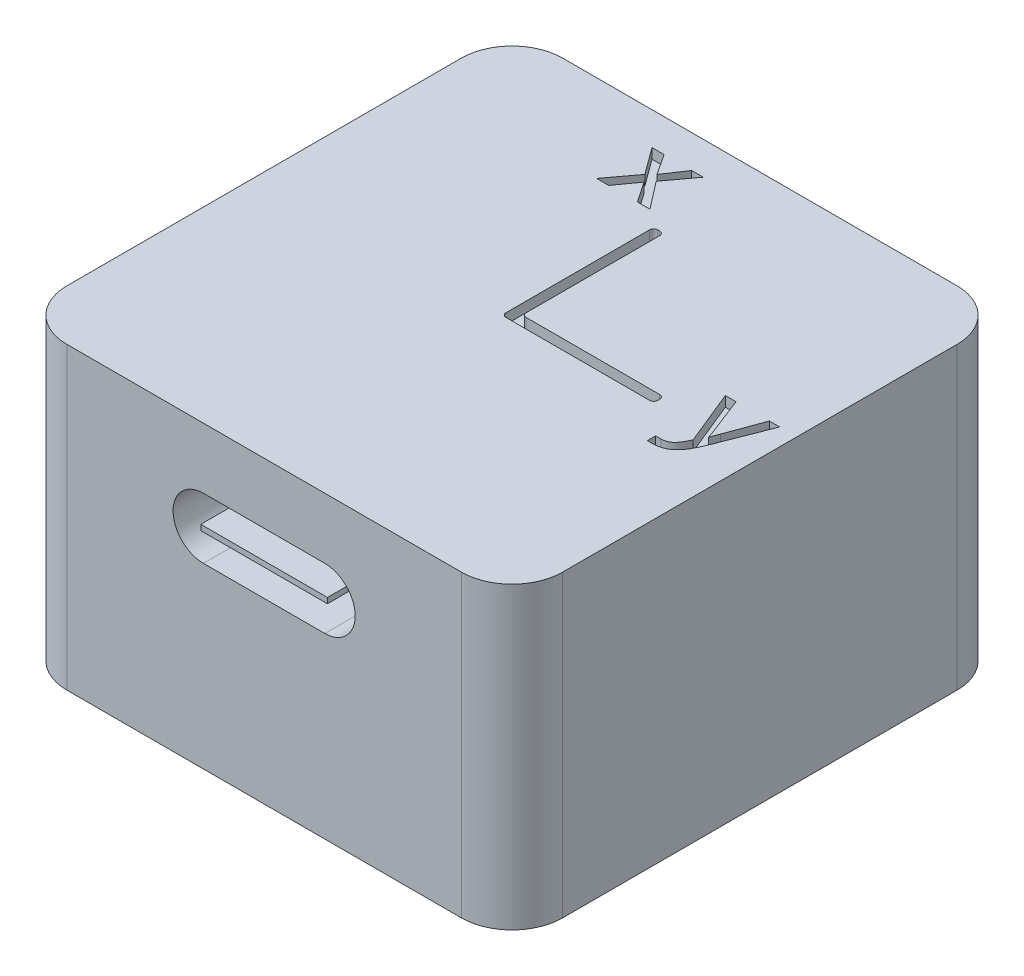
from build123d import *

# Parameters (mm, degrees)
EXTRUDE_1_DEPTH     = 14.8
CUT_EXTRUDE_1_DEPTH = 0.5
CUT_EXTRUDE_2_DEPTH = 0.5
CUT_EXTRUDE_3_DEPTH = 0.5
CUT_EXTRUDE_4_DEPTH = 5
SKETCH_6_W          = 6.25953497
SKETCH_6_H          = 0.270195754
EXTRUDE_2_DEPTH     = 5


with BuildPart() as part:
    # 草图1 → 凸台-拉伸1 (new body)
    with BuildSketch(Plane(origin=(0, 0, 0), x_dir=(1, 0, 0), z_dir=(0, 1, 0))):
        with BuildLine():
            Line((-9.75, 12.25), (9.75, 12.25))
            ThreePointArc((9.75, 12.25), (11.517766953, 11.517766953), (12.25, 9.75))
            Line((12.25, 9.75), (12.25, -9.75))
            ThreePointArc((12.25, -9.75), (11.517766953, -11.517766953), (9.75, -12.25))
            Line((9.75, -12.25), (-9.75, -12.25))
            ThreePointArc((-9.75, -12.25), (-11.517766953, -11.517766953), (-12.25, -9.75))
            Line((-12.25, -9.75), (-12.25, 9.75))
            ThreePointArc((-12.25, 9.75), (-11.517766953, 11.517766953), (-9.75, 12.25))
        make_face()
    extrude(amount=EXTRUDE_1_DEPTH)

    # 草图2 → 切除-拉伸1 (cut)
    with BuildSketch(Plane(origin=(0, 14.8, 0), x_dir=(1, 0, 0), z_dir=(0, 1, 0))):
        with BuildLine():
            Line((-0.25, -0.05), (-0.25, 7.05))
            ThreePointArc((-0.25, 7.05), (-0.191421356, 7.191421356), (-0.05, 7.25))
            Line((-0.05, 7.25), (0.05, 7.25))
            ThreePointArc((0.05, 7.25), (0.191421356, 7.191421356), (0.25, 7.05))
            Line((0.25, 7.05), (0.25, 0.45))
            ThreePointArc((0.25, 0.45), (0.308578644, 0.308578644), (0.45, 0.25))
            Line((0.45, 0.25), (7.05, 0.25))
            ThreePointArc((7.05, 0.25), (7.191421356, 0.191421356), (7.25, 0.05))
            Line((7.25, 0.05), (7.25, -0.05))
            ThreePointArc((7.25, -0.05), (7.191421356, -0.191421356), (7.05, -0.25))
            Line((7.05, -0.25), (-0.05, -0.25))
            ThreePointArc((-0.05, -0.25), (-0.191421356, -0.191421356), (-0.25, -0.05))
        make_face()
    extrude(amount=-CUT_EXTRUDE_1_DEPTH, mode=Mode.SUBTRACT)

    # 草图3 → 切除-拉伸2 (cut)
    with BuildSketch(Plane(origin=(0, 14.8, 0), x_dir=(1, 0, 0), z_dir=(0, 1, 0))):
        Polygon((-1.12229135, 7.940311498), (-1.739705299, 7.940311498), (-2.429243342, 8.953219107), (-3.157617436, 7.940311498), (-3.759972509, 7.940311498), (-2.739139176, 9.303536136), (-3.709247871, 10.628717295), (-3.112440806, 10.628717295), (-2.437961639, 9.603128527), (-1.747631023, 10.628717295), (-1.173015987, 10.628717295), (-2.164524139, 9.286892114), align=None)
    extrude(amount=-CUT_EXTRUDE_2_DEPTH, mode=Mode.SUBTRACT)

    # 草图4 → 切除-拉伸3 (cut)
    with BuildSketch(Plane(origin=(0, 14.8, 0), x_dir=(1, 0, 0), z_dir=(0, 1, 0))):
        with BuildLine():
            Line((11.403475674, 1.828812442), (10.465069877, -0.571096978))
            add(Edge.make_bspline(
                [(10.465069877, -0.571096978), (10.441698651, -0.632813146), (10.396273738, -0.752766273), (10.323476502, -0.924688355), (10.248962895, -1.083206918), (10.173859339, -1.229075957), (10.096249765, -1.36191233), (10.015608226, -1.4823536), (9.930382332, -1.589561424), (9.842668967, -1.685533109), (9.749809923, -1.768599434), (9.653342166, -1.840372882), (9.551769454, -1.8996192), (9.445588671, -1.946527543), (9.334028283, -1.98269443), (9.216553101, -2.007284146), (9.092822913, -2.024191262), (9.008117337, -2.025559298), (8.964730203, -2.026260022)],
                knots=[0, 0, 0, 0, 0.000197967, 0.000384774, 0.000559923, 0.000723343, 0.00087681, 0.001021234, 0.001157764, 0.001287322, 0.001410801, 0.001530959, 0.001647456, 0.001762775, 0.001878572, 0.001998583, 0.00212245, 0.002252519, 0.002252519, 0.002252519, 0.002252519], degree=3))
            add(Edge.make_bspline(
                [(8.964730203, -2.026260022), (8.942538174, -2.026260022), (8.900531833, -2.026260022), (8.838975372, -2.026260022), (8.777947292, -2.026260022), (8.736733524, -2.026260022), (8.715069877, -2.026260022)],
                knots=[0, 0, 0, 0, 6.6576e-05, 0.000126019, 0.000184669, 0.00024966, 0.00024966, 0.00024966, 0.00024966], degree=3))
            Line((8.715069877, -2.026260022), (8.715069877, -1.62046292))
            add(Edge.make_bspline(
                [(8.715069877, -1.62046292), (8.735676761, -1.62046292), (8.778739865, -1.62046292), (8.845844333, -1.62046292), (8.917440046, -1.62046292), (8.966579539, -1.62046292), (8.991677667, -1.62046292)],
                knots=[0, 0, 0, 0, 6.1821e-05, 0.000129189, 0.000201313, 0.000276608, 0.000276608, 0.000276608, 0.000276608], degree=3))
            add(Edge.make_bspline(
                [(8.991677667, -1.62046292), (9.033605397, -1.618534602), (9.115432431, -1.614771255), (9.214758532, -1.588635211), (9.288887696, -1.557320953), (9.342163605, -1.526264237), (9.395038901, -1.491140236), (9.444860635, -1.447343482), (9.494119782, -1.39811915), (9.542666617, -1.342303846), (9.589955098, -1.279758499), (9.636344058, -1.210191532), (9.680981598, -1.132997619), (9.726689194, -1.049181552), (9.769706918, -0.956871513), (9.797608369, -0.892680567), (9.811990167, -0.859593355)],
                knots=[0, 0, 0, 0, 0.00012565, 0.00024522, 0.000305581, 0.00036663, 0.000429941, 0.000495706, 0.000565199, 0.000638789, 0.000717414, 0.000800286, 0.000889457, 0.000984846, 0.001086595, 0.001194832, 0.001194832, 0.001194832, 0.001194832], degree=3))
            Line((9.811990167, -0.859593355), (8.715069877, 1.828812442))
            Line((8.715069877, 1.828812442), (9.244508282, 1.828812442))
            Line((9.244508282, 1.828812442), (9.944349768, 0.025710087))
            Line((9.944349768, 0.025710087), (10.084635094, -0.366613282))
            Line((10.084635094, -0.366613282), (10.244734732, 0.061375848))
            Line((10.244734732, 0.061375848), (10.892266435, 1.828812442))
            Line((10.892266435, 1.828812442), (11.403475674, 1.828812442))
        make_face()
    extrude(amount=-CUT_EXTRUDE_3_DEPTH, mode=Mode.SUBTRACT)

    # 草图5 → 切除-拉伸4 (cut)
    with BuildSketch(Plane.XY.offset(12.25)):
        with BuildLine():
            Line((-3, 11.8), (3, 11.8))
            ThreePointArc((3, 11.8), (4.5, 10.3), (3, 8.8))
            Line((3, 8.8), (-3, 8.8))
            ThreePointArc((-3, 8.8), (-4.5, 10.3), (-3, 11.8))
        make_face()
    extrude(amount=-CUT_EXTRUDE_4_DEPTH, mode=Mode.SUBTRACT)

    # 草图6 → 凸台-拉伸2 (add)
    with BuildSketch(Plane.XY.offset(7.25)):
        with Locations((0, 10.270829887)):
            Rectangle(SKETCH_6_W, SKETCH_6_H)
    extrude(amount=EXTRUDE_2_DEPTH)


solid = part.part
